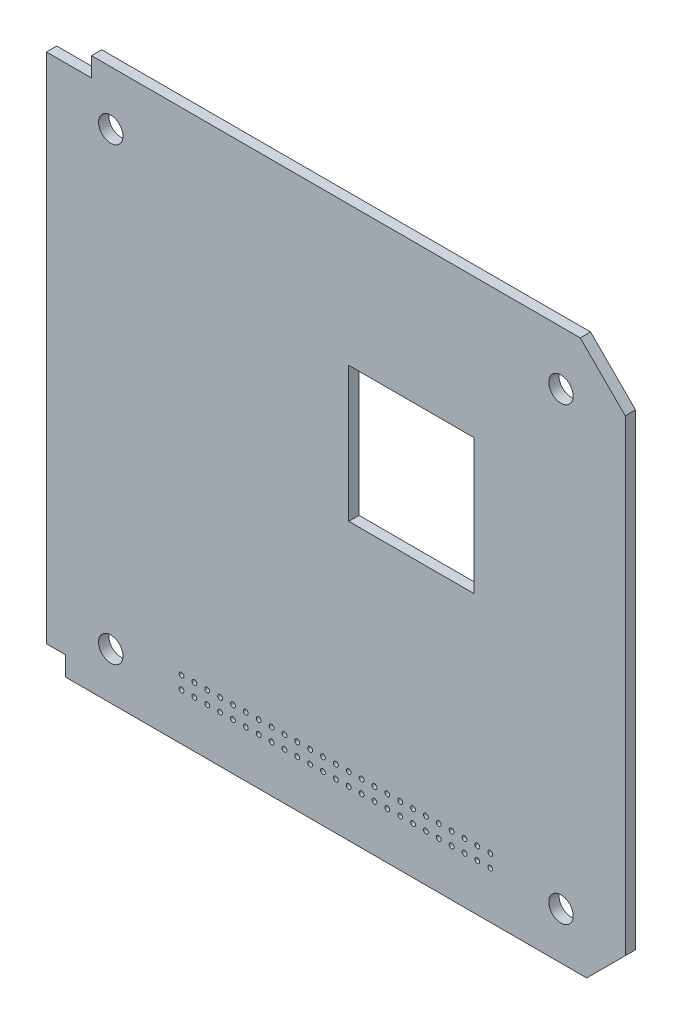
from build123d import *

# Parameters (mm, degrees)
SKETCH1_R           = 1.9
SKETCH1_R_2         = 0.375
BOSS_EXTRUDE1_DEPTH = 1.6
SKETCH_1_W          = 19.5
SKETCH_1_H          = 21
CUT_EXTRUDE_1_DEPTH = 10
SKETCH_2_W          = 7
SKETCH_2_H          = 3
CUT_EXTRUDE_2_DEPTH = 10


with BuildPart() as part:
    # Sketch1 → Boss-Extrude1 (new body)
    with BuildSketch(Plane.XY):
        Polygon((90, -79.7), (90, 0), (0, 0), (0, -82.7), (3, -82.7), (3, -85.7), (84, -85.7), align=None)
        with Locations((10, -78.4)):
            Circle(SKETCH1_R, mode=Mode.SUBTRACT)
        with Locations((10, -8.4)):
            Circle(SKETCH1_R, mode=Mode.SUBTRACT)
        with Locations((80, -8.4)):
            Circle(SKETCH1_R, mode=Mode.SUBTRACT)
        with Locations((80, -78.4)):
            Circle(SKETCH1_R, mode=Mode.SUBTRACT)
        with Locations((21, -76.4)):
            Circle(SKETCH1_R_2, mode=Mode.SUBTRACT)
        with Locations((23, -76.4)):
            Circle(SKETCH1_R_2, mode=Mode.SUBTRACT)
        with Locations((25, -76.4)):
            Circle(SKETCH1_R_2, mode=Mode.SUBTRACT)
        with Locations((27, -76.4)):
            Circle(SKETCH1_R_2, mode=Mode.SUBTRACT)
        with Locations((29, -76.4)):
            Circle(SKETCH1_R_2, mode=Mode.SUBTRACT)
        with Locations((31, -76.4)):
            Circle(SKETCH1_R_2, mode=Mode.SUBTRACT)
        with Locations((33, -76.4)):
            Circle(SKETCH1_R_2, mode=Mode.SUBTRACT)
        with Locations((35, -76.4)):
            Circle(SKETCH1_R_2, mode=Mode.SUBTRACT)
        with Locations((37, -76.4)):
            Circle(SKETCH1_R_2, mode=Mode.SUBTRACT)
        with Locations((39, -76.4)):
            Circle(SKETCH1_R_2, mode=Mode.SUBTRACT)
        with Locations((41, -76.4)):
            Circle(SKETCH1_R_2, mode=Mode.SUBTRACT)
        with Locations((43, -76.4)):
            Circle(SKETCH1_R_2, mode=Mode.SUBTRACT)
        with Locations((45, -76.4)):
            Circle(SKETCH1_R_2, mode=Mode.SUBTRACT)
        with Locations((47, -76.4)):
            Circle(SKETCH1_R_2, mode=Mode.SUBTRACT)
        with Locations((49, -76.4)):
            Circle(SKETCH1_R_2, mode=Mode.SUBTRACT)
        with Locations((51, -76.4)):
            Circle(SKETCH1_R_2, mode=Mode.SUBTRACT)
        with Locations((53, -76.4)):
            Circle(SKETCH1_R_2, mode=Mode.SUBTRACT)
        with Locations((55, -76.4)):
            Circle(SKETCH1_R_2, mode=Mode.SUBTRACT)
        with Locations((57, -76.4)):
            Circle(SKETCH1_R_2, mode=Mode.SUBTRACT)
        with Locations((59, -76.4)):
            Circle(SKETCH1_R_2, mode=Mode.SUBTRACT)
        with Locations((61, -76.4)):
            Circle(SKETCH1_R_2, mode=Mode.SUBTRACT)
        with Locations((63, -76.4)):
            Circle(SKETCH1_R_2, mode=Mode.SUBTRACT)
        with Locations((65, -76.4)):
            Circle(SKETCH1_R_2, mode=Mode.SUBTRACT)
        with Locations((67, -76.4)):
            Circle(SKETCH1_R_2, mode=Mode.SUBTRACT)
        with Locations((69, -76.4)):
            Circle(SKETCH1_R_2, mode=Mode.SUBTRACT)
        with Locations((23, -78.4)):
            Circle(SKETCH1_R_2, mode=Mode.SUBTRACT)
        with Locations((25, -78.4)):
            Circle(SKETCH1_R_2, mode=Mode.SUBTRACT)
        with Locations((27, -78.4)):
            Circle(SKETCH1_R_2, mode=Mode.SUBTRACT)
        with Locations((29, -78.4)):
            Circle(SKETCH1_R_2, mode=Mode.SUBTRACT)
        with Locations((31, -78.4)):
            Circle(SKETCH1_R_2, mode=Mode.SUBTRACT)
        with Locations((33, -78.4)):
            Circle(SKETCH1_R_2, mode=Mode.SUBTRACT)
        with Locations((35, -78.4)):
            Circle(SKETCH1_R_2, mode=Mode.SUBTRACT)
        with Locations((37, -78.4)):
            Circle(SKETCH1_R_2, mode=Mode.SUBTRACT)
        with Locations((39, -78.4)):
            Circle(SKETCH1_R_2, mode=Mode.SUBTRACT)
        with Locations((41, -78.4)):
            Circle(SKETCH1_R_2, mode=Mode.SUBTRACT)
        with Locations((43, -78.4)):
            Circle(SKETCH1_R_2, mode=Mode.SUBTRACT)
        with Locations((45, -78.4)):
            Circle(SKETCH1_R_2, mode=Mode.SUBTRACT)
        with Locations((47, -78.4)):
            Circle(SKETCH1_R_2, mode=Mode.SUBTRACT)
        with Locations((49, -78.4)):
            Circle(SKETCH1_R_2, mode=Mode.SUBTRACT)
        with Locations((51, -78.4)):
            Circle(SKETCH1_R_2, mode=Mode.SUBTRACT)
        with Locations((53, -78.4)):
            Circle(SKETCH1_R_2, mode=Mode.SUBTRACT)
        with Locations((55, -78.4)):
            Circle(SKETCH1_R_2, mode=Mode.SUBTRACT)
        with Locations((57, -78.4)):
            Circle(SKETCH1_R_2, mode=Mode.SUBTRACT)
        with Locations((59, -78.4)):
            Circle(SKETCH1_R_2, mode=Mode.SUBTRACT)
        with Locations((61, -78.4)):
            Circle(SKETCH1_R_2, mode=Mode.SUBTRACT)
        with Locations((63, -78.4)):
            Circle(SKETCH1_R_2, mode=Mode.SUBTRACT)
        with Locations((65, -78.4)):
            Circle(SKETCH1_R_2, mode=Mode.SUBTRACT)
        with Locations((67, -78.4)):
            Circle(SKETCH1_R_2, mode=Mode.SUBTRACT)
        with Locations((69, -78.4)):
            Circle(SKETCH1_R_2, mode=Mode.SUBTRACT)
        with Locations((21, -78.4)):
            Circle(SKETCH1_R_2, mode=Mode.SUBTRACT)
    extrude(amount=BOSS_EXTRUDE1_DEPTH)

    # ｽｹｯﾁ1 → ｶｯﾄ - 押し出し1 (cut)
    with BuildSketch(Plane.XY.offset(1.6)):
        with Locations((56.75, -32.2)):
            Rectangle(SKETCH_1_W, SKETCH_1_H)
    extrude(amount=-CUT_EXTRUDE_1_DEPTH, mode=Mode.SUBTRACT)

    # ｽｹｯﾁ2 → ｶｯﾄ - 押し出し2 (cut)
    with BuildSketch(Plane.XY.offset(1.6)):
        Polygon((90, 0), (90, -7), (83, 0), align=None)
        with Locations((3.5, -1.5)):
            Rectangle(SKETCH_2_W, SKETCH_2_H)
    extrude(amount=-CUT_EXTRUDE_2_DEPTH, mode=Mode.SUBTRACT)


solid = part.part
